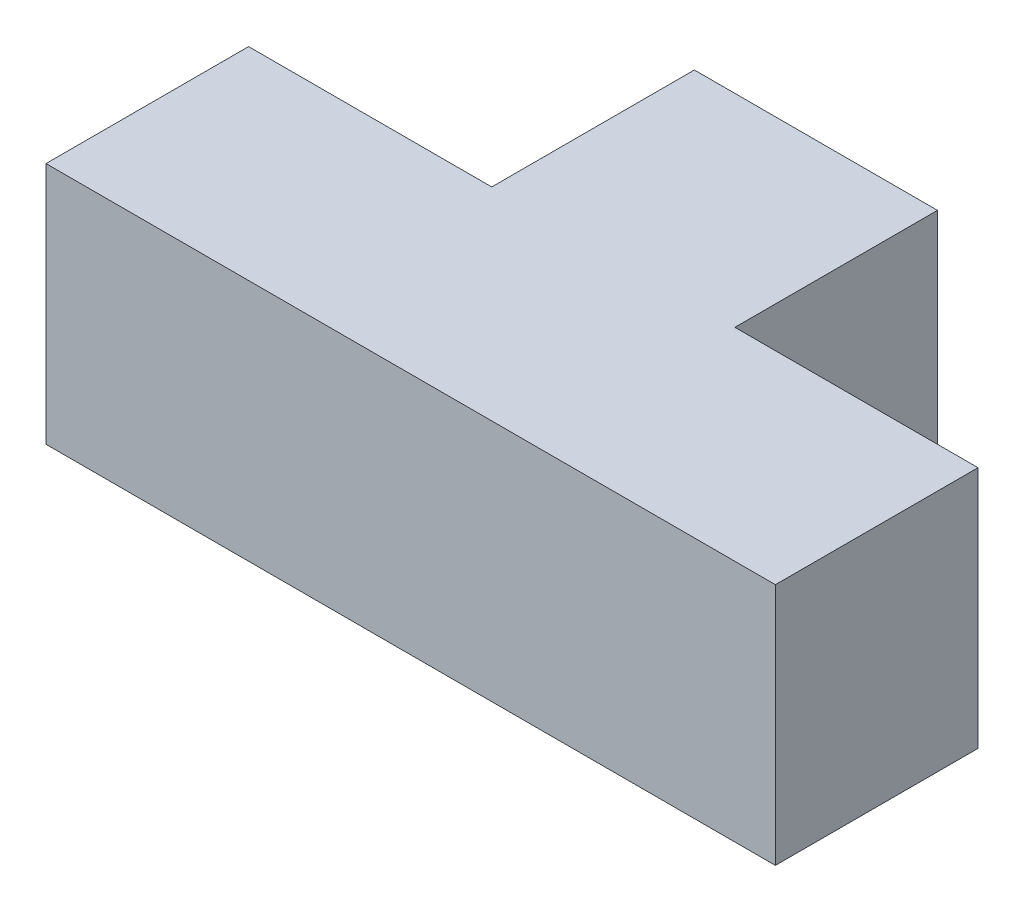
from build123d import *

# Parameters (mm, degrees)
BOSS_EXTRUDE1_DEPTH = 30


with BuildPart() as part:
    # Sketch1 → Boss-Extrude1 (new body)
    with BuildSketch(Plane(origin=(0, 0, 0), x_dir=(1, 0, 0), z_dir=(0, 1, 0))):
        Polygon((0, 0), (90, 0), (90, 25), (60, 25), (60, 50), (30, 50), (30, 25), (0, 25), align=None)
    extrude(amount=BOSS_EXTRUDE1_DEPTH)


solid = part.part
